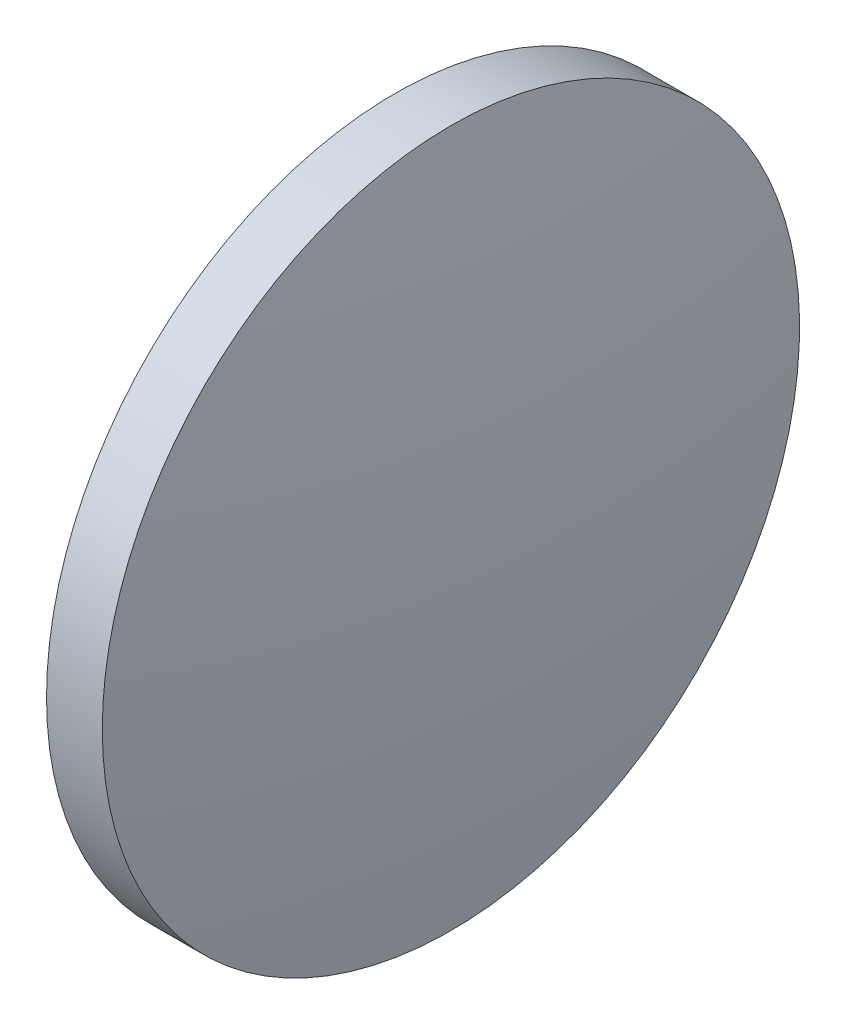
from build123d import *


with BuildPart() as part:
    # 草图1 → 旋转1 (revolve)
    with BuildSketch(Plane.XY):
        with BuildLine():
            Line((1228.948058844, 317.435345417), (1228.948058844, 329.935345417))
            Line((1228.948058844, 329.935345417), (1230.948058844, 329.935345417))
            ThreePointArc((1230.948058844, 329.935345417), (1231.660216881, 323.703369428), (1231.898058844, 317.435345417))
            Line((1231.898058844, 317.435345417), (1228.948058844, 317.435345417))
        make_face()
    revolve(axis=Axis((1224.206027602, 317.435345417, 0), (1, 0, 0)))


solid = part.part
